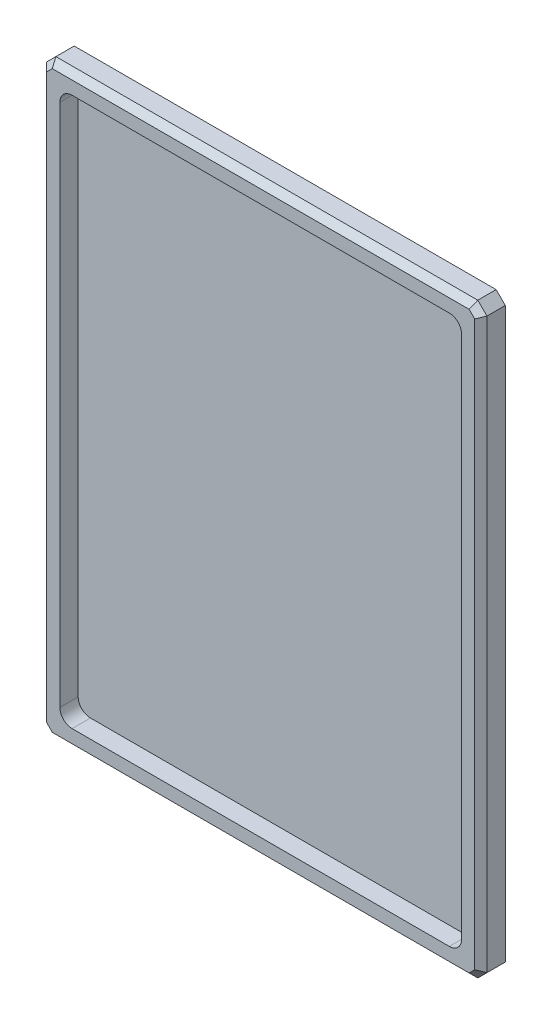
from build123d import *

# Parameters (mm, degrees)
SKETCH1_W           = 228.6
SKETCH1_H           = 304.8
BOSS_EXTRUDE1_DEPTH = 12.7
CUT_EXTRUDE1_DEPTH  = 9.525
CHAMFER1_SIZE       = 4.7625
CHAMFER2_SIZE       = 3.175


with BuildPart() as part:
    # Sketch1 → Boss-Extrude1 (new body)
    with BuildSketch(Plane.XY):
        Rectangle(SKETCH1_W, SKETCH1_H)
    extrude(amount=BOSS_EXTRUDE1_DEPTH)

    # Sketch2 → Cut-Extrude1 (cut)
    with BuildSketch(Plane.XY.offset(12.7)):
        with BuildLine():
            Line((97.95, -142.4), (-97.95, -142.4))
            ThreePointArc((-97.95, -142.4), (-102.440128061, -140.540128061), (-104.3, -136.05))
            Line((-104.3, -136.05), (-104.3, 136.05))
            ThreePointArc((-104.3, 136.05), (-102.440128061, 140.540128061), (-97.95, 142.4))
            Line((-97.95, 142.4), (97.95, 142.4))
            ThreePointArc((97.95, 142.4), (102.440128061, 140.540128061), (104.3, 136.05))
            Line((104.3, 136.05), (104.3, -136.05))
            ThreePointArc((104.3, -136.05), (102.440128061, -140.540128061), (97.95, -142.4))
        make_face()
    extrude(amount=-CUT_EXTRUDE1_DEPTH, mode=Mode.SUBTRACT)

    # Chamfer1
    chamfer1_edges = [part.edges().sort_by_distance(p)[0] for p in [
        (-114.3, 152.4, 6.35),
        (114.3, 152.4, 6.35),
        (114.3, -152.4, 6.35),
        (-114.3, -152.4, 6.35),
    ]]
    chamfer(chamfer1_edges, length=CHAMFER1_SIZE)

    # Chamfer2
    chamfer2_edges = [part.edges().sort_by_distance(p)[0] for p in [
        (0, -152.4, 12.7),
        (-114.3, 0, 12.7),
        (114.3, 0, 12.7),
        (0, 152.4, 12.7),
        (111.91875, 150.01875, 12.7),
        (-111.91875, 150.01875, 12.7),
        (111.91875, -150.01875, 12.7),
        (-111.91875, -150.01875, 12.7),
    ]]
    chamfer(chamfer2_edges, length=CHAMFER2_SIZE)


solid = part.part
